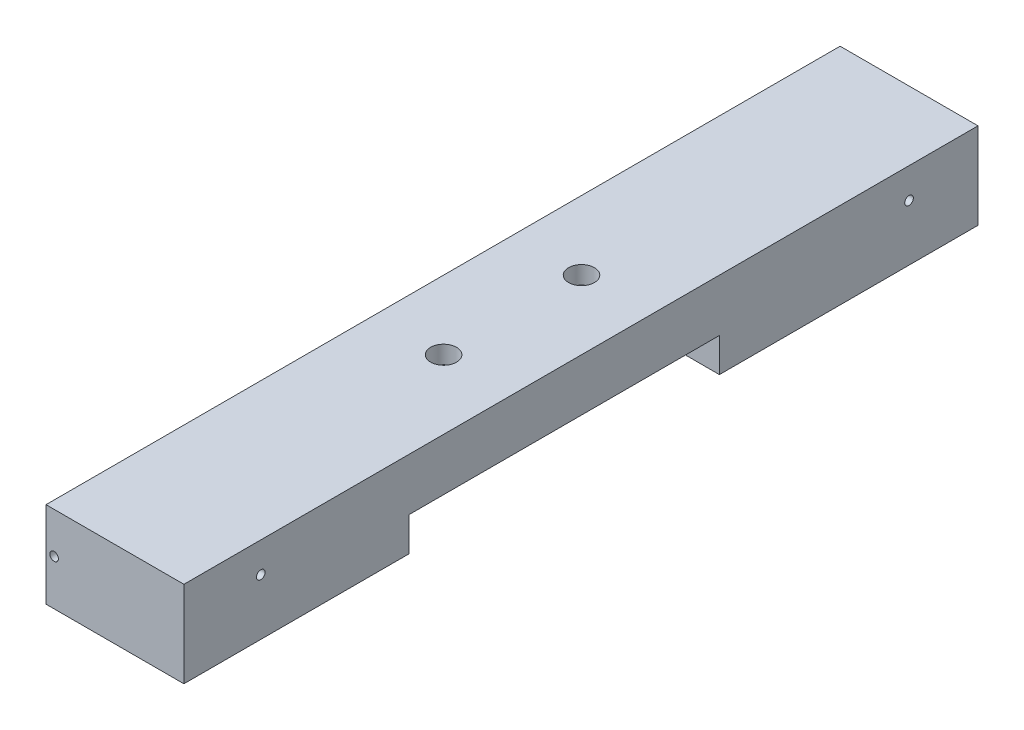
from build123d import *

# Parameters (mm, degrees)
SKETCH1_W           = 101.6
SKETCH1_H           = 63.5
BOSS_EXTRUDE1_DEPTH = 585.0001
SKETCH2_W           = 228.6
SKETCH2_H           = 25
CUT_EXTRUDE1_DEPTH  = 102.6
SKETCH5_R           = 1.75
CUT_EXTRUDE4_DEPTH  = 6.35
SKETCH5_3_R         = 3.3
CUT_EXTRUDE5_DEPTH  = 25.4
SKETCH6_R           = 4.934351916
CUT_EXTRUDE6_DEPTH  = 39.5
CUT_EXTRUDE7_DEPTH  = 12.7
SKETCH8_R           = 3.175
CUT_EXTRUDE8_DEPTH  = 12.7
CUT_EXTRUDE9_START  = 50.8
SKETCH9_R           = 9.525
CUT_EXTRUDE9_DEPTH  = 14.1


with BuildPart() as part:
    # Sketch1 → Boss-Extrude1 (new body)
    with BuildSketch(Plane.XY):
        with Locations((50.8, 31.75)):
            Rectangle(SKETCH1_W, SKETCH1_H)
    extrude(amount=BOSS_EXTRUDE1_DEPTH)

    # Sketch2 → Cut-Extrude1 (cut, through all)
    with BuildSketch(Plane.ZY):
        with Locations((304.8, 12.5)):
            Rectangle(SKETCH2_W, SKETCH2_H)
    extrude(amount=-CUT_EXTRUDE1_DEPTH, mode=Mode.SUBTRACT)

    # Sketch5 → Cut-Extrude4 (cut)
    with BuildSketch(Plane.ZY):
        with Locations((530, 33.5)):
            Circle(SKETCH5_R)
        with Locations((470, 33.5)):
            Circle(SKETCH5_R)
        with Locations((410, 33.5)):
            Circle(SKETCH5_R)
        with Locations((350, 33.5)):
            Circle(SKETCH5_R)
        with Locations((290, 33.5)):
            Circle(SKETCH5_R)
        with Locations((230, 33.5)):
            Circle(SKETCH5_R)
        with Locations((170, 33.5)):
            Circle(SKETCH5_R)
        with Locations((110, 33.5)):
            Circle(SKETCH5_R)
        with Locations((50, 33.5)):
            Circle(SKETCH5_R)
    extrude(amount=-CUT_EXTRUDE4_DEPTH, mode=Mode.SUBTRACT)

    # Sketch5_3 → Cut-Extrude5 (cut)
    with BuildSketch(Plane.ZY):
        with Locations((579, 10.5)):
            Circle(SKETCH5_3_R)
        with Locations((566, 10.5)):
            Circle(SKETCH5_3_R)
        with Locations((579, 56.5)):
            Circle(SKETCH5_3_R)
        with Locations((566, 56.5)):
            Circle(SKETCH5_3_R)
        with Locations((10, 10.5)):
            Circle(SKETCH5_3_R)
        with Locations((10, 56.5)):
            Circle(SKETCH5_3_R)
    extrude(amount=-CUT_EXTRUDE5_DEPTH, mode=Mode.SUBTRACT)

    # Sketch6 → Cut-Extrude6 (cut, through all)
    with BuildSketch(Plane.XZ.offset(-25)):
        with Locations((50.8, 342.9)):
            Circle(SKETCH6_R)
        with Locations((50.8, 241.3)):
            Circle(SKETCH6_R)
    extrude(amount=-CUT_EXTRUDE6_DEPTH, mode=Mode.SUBTRACT)

    # Sketch7 → Cut-Extrude7 (cut)
    with BuildSketch(Plane(origin=(101.6, 0, 0), x_dir=(0, 0, -1), z_dir=(1, 0, 0))):
        with BuildLine():
            ThreePointArc((-53.548542941, 39.694194493), (-50.80220266, 38.11238), (-48.055862379, 39.694194493))
            ThreePointArc((-48.055862379, 39.694194493), (-47.62720266, 41.28738), (-48.055862379, 42.880565507))
            ThreePointArc((-48.055862379, 42.880565507), (-50.80220266, 44.46238), (-53.548542941, 42.880565507))
            ThreePointArc((-53.548542941, 42.880565507), (-53.97720266, 41.28738), (-53.548542941, 39.694194493))
        make_face()
        with BuildLine():
            ThreePointArc((-525.637642589, 39.694194493), (-525.20898287, 41.28738), (-525.637642589, 42.880565507))
            ThreePointArc((-525.637642589, 42.880565507), (-528.38398287, 44.46238), (-531.130323151, 42.880565507))
            ThreePointArc((-531.130323151, 42.880565507), (-531.55898287, 41.28738), (-531.130323151, 39.694194493))
            ThreePointArc((-531.130323151, 39.694194493), (-528.38398287, 38.11238), (-525.637642589, 39.694194493))
        make_face()
    extrude(amount=-CUT_EXTRUDE7_DEPTH, mode=Mode.SUBTRACT)

    # Sketch8 → Cut-Extrude8 (cut)
    with BuildSketch(Plane.XY.offset(585.0001)):
        with Locations((5.95, 33.5)):
            Circle(SKETCH8_R)
    extrude(amount=-CUT_EXTRUDE8_DEPTH, mode=Mode.SUBTRACT)

    # Sketch9 → Cut-Extrude9 (cut, through all)
    with BuildSketch(Plane(origin=(0, -0.4, 0), x_dir=(1, 0, 0), z_dir=(0, 1, 0)).offset(CUT_EXTRUDE9_START)):
        with Locations((50.8, -342.9)):
            Circle(SKETCH9_R)
        with Locations((50.8, -241.3)):
            Circle(SKETCH9_R)
    extrude(amount=CUT_EXTRUDE9_DEPTH, mode=Mode.SUBTRACT)


solid = part.part
